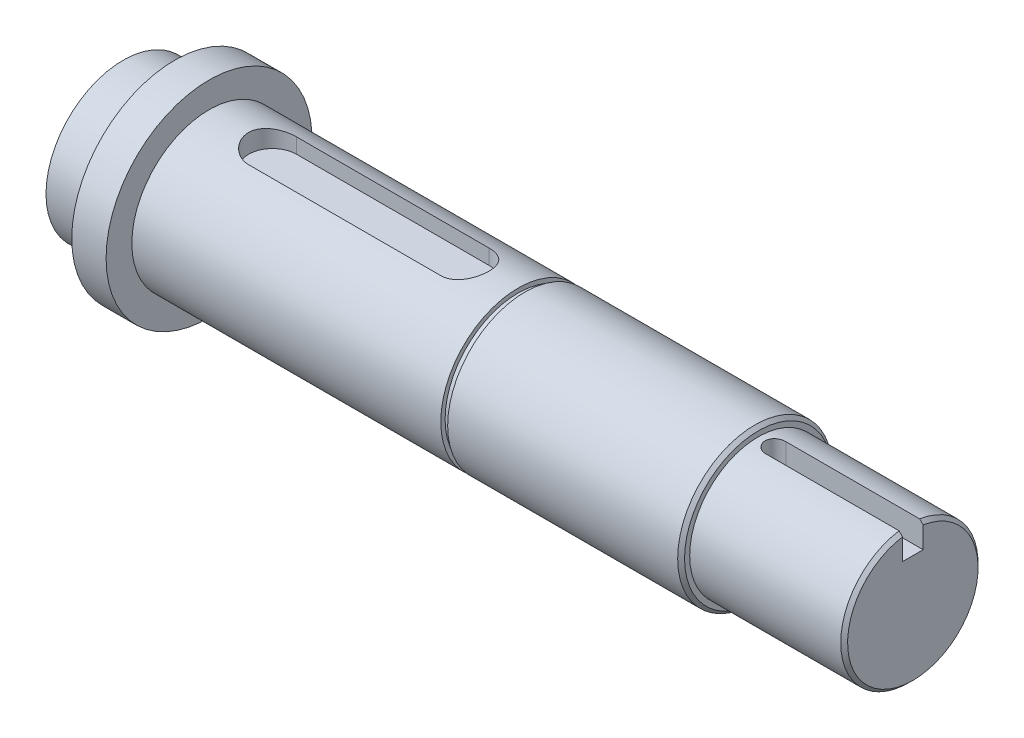
from build123d import *

# Parameters (mm, degrees)
ZKOSEN_1_SIZE            = 1
ODEBRAT_VYSUNUT_M1_DEPTH = 7.5
ODEBRAT_VYSUNUT_M2_DEPTH = 5.5


with BuildPart() as part:
    # Skica1 → Rotovat1 (revolve)
    with BuildSketch(Plane.XY):
        Polygon((0, 0), (0, 22.5), (15, 22.5), (15, 30), (25, 30), (25, 22.5), (115, 22.5), (115, 21.25), (117, 21.25), (117, 22.5), (185, 22.5), (185, 20), (230, 20), (230, 0), align=None)
    revolve(axis=Axis((-258.80539499, 0, 0), (1, 0, 0)))

    # Zkosení1
    zkosen_1_edges = [part.edges().sort_by_distance(p)[0] for p in [
        (185, -22.5, 0),
        (230, -20, 0),
    ]]
    chamfer(zkosen_1_edges, length=ZKOSEN_1_SIZE)

    # Skica6 → Odebrat vysunutím1 (cut)
    with BuildSketch(Plane(origin=(0, 20, 0), x_dir=(1, 0, 0), z_dir=(0, 1, 0))):
        with BuildLine():
            Line((230, -3), (190, -3))
            ThreePointArc((190, -3), (187, 0), (190, 3))
            Line((190, 3), (230, 3))
            ThreePointArc((230, 3), (233, 0), (230, -3))
        make_face()
    extrude(amount=-ODEBRAT_VYSUNUT_M1_DEPTH, mode=Mode.SUBTRACT)

    # Skica7 → Odebrat vysunutím2 (cut)
    with BuildSketch(Plane(origin=(0, 22.5, 0), x_dir=(1, 0, 0), z_dir=(0, 1, 0))):
        with BuildLine():
            Line((43.5, 7), (99.5, 7))
            ThreePointArc((99.5, 7), (106.5, 0), (99.5, -7))
            Line((99.5, -7), (43.5, -7))
            ThreePointArc((43.5, -7), (36.5, 0), (43.5, 7))
        make_face()
    extrude(amount=-ODEBRAT_VYSUNUT_M2_DEPTH, mode=Mode.SUBTRACT)


solid = part.part
